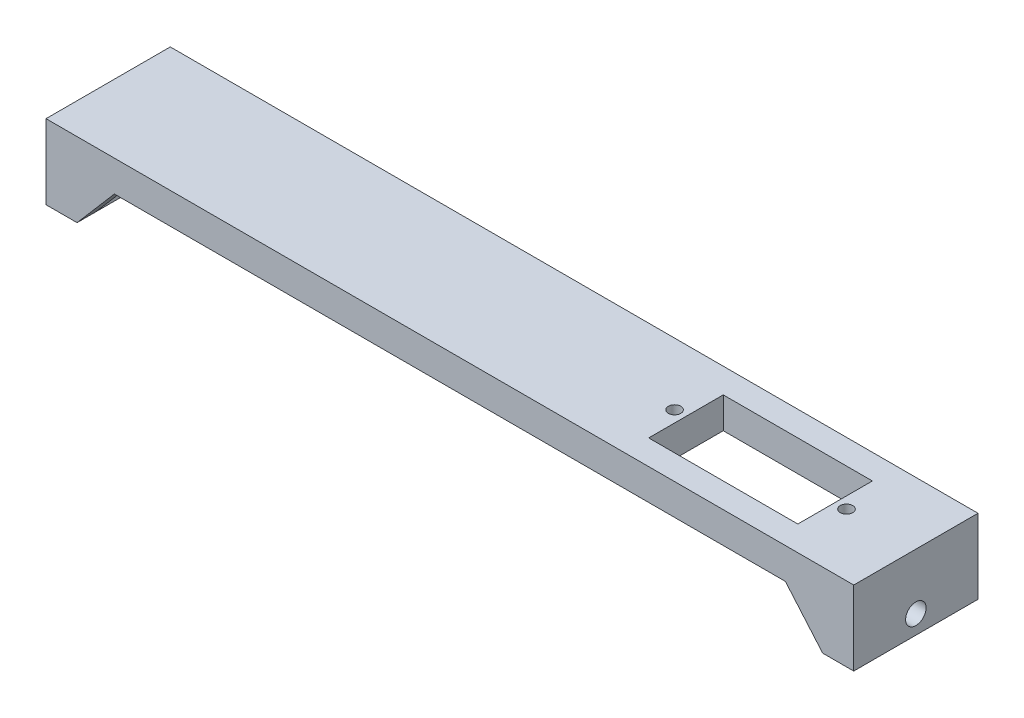
from build123d import *

# Parameters (mm, degrees)
EXTRUDE_2_DEPTH          = 20
SKETCH_3_R               = 1.65
CUT_EXTRUDE_1_DEPTH      = 126
CUT_EXTRUDE_1_DEPTH_BACK = 6
EXTRUDE_3_DEPTH          = 3
MIRROR_2_COPY_1_DEPTH    = 3
SKETCH_7_W               = 24
SKETCH_7_H               = 12
CUT_EXTRUDE_2_DEPTH      = 5
SKETCH_10_R              = 1
CUT_EXTRUDE_3_DEPTH      = 5


with BuildPart() as part:
    # 草图1 → 凸台-拉伸2 (new body)
    with BuildSketch(Plane.XY):
        Polygon((-65, 0), (65, 0), (65, -12), (60, -12), (60, -5), (-60, -5), (-60, -12), (-65, -12), align=None)
    extrude(amount=EXTRUDE_2_DEPTH)

    # 草图3 → 切除-拉伸1 (cut, two sides)
    with BuildSketch(Plane(origin=(-60, 0, 0), x_dir=(0, 0, -1), z_dir=(1, 0, 0))) as cut_extrude_1_sk:
        with Locations((-10, -9)):
            Circle(SKETCH_3_R)
    extrude(amount=CUT_EXTRUDE_1_DEPTH, mode=Mode.SUBTRACT)
    extrude(cut_extrude_1_sk.sketch, amount=-CUT_EXTRUDE_1_DEPTH_BACK, mode=Mode.SUBTRACT)

    # 草图4 → 凸台-拉伸3 (add)
    with BuildSketch(Plane(origin=(0, 0, 0), x_dir=(-1, 0, 0), z_dir=(0, 0, -1))):
        Polygon((54, -5), (60, -12), (60, -5), align=None)
    extrude_3 = extrude(amount=-EXTRUDE_3_DEPTH)

    # 镜向1: 凸台-拉伸3 across plane
    add(extrude_3.mirror(Plane.XY.offset(10)))

    # 镜向2: 凸台-拉伸3 across plane
    add(extrude_3.mirror(Plane(origin=(0, 0, 0), x_dir=(0, 0, 1), z_dir=(1, 0, 0))))

    # 镜向2 copy 1 sketch → 镜向2 copy 1 (add)
    with BuildSketch(Plane.XY.offset(20)):
        Polygon((54, -5), (60, -12), (60, -5), align=None)
    extrude(amount=-MIRROR_2_COPY_1_DEPTH)

    # 草图7 → 切除-拉伸2 (cut)
    with BuildSketch(Plane.XZ.offset(5)):
        with Locations((40, 10)):
            Rectangle(SKETCH_7_W, SKETCH_7_H)
    extrude(amount=-CUT_EXTRUDE_2_DEPTH, mode=Mode.SUBTRACT)

    # 草图10 → 切除-拉伸3 (cut)
    with BuildSketch(Plane.XZ.offset(5)):
        with Locations((53.835, 10)):
            Circle(SKETCH_10_R)
        with Locations((26.165, 10)):
            Circle(SKETCH_10_R)
    extrude(amount=-CUT_EXTRUDE_3_DEPTH, mode=Mode.SUBTRACT)


solid = part.part
